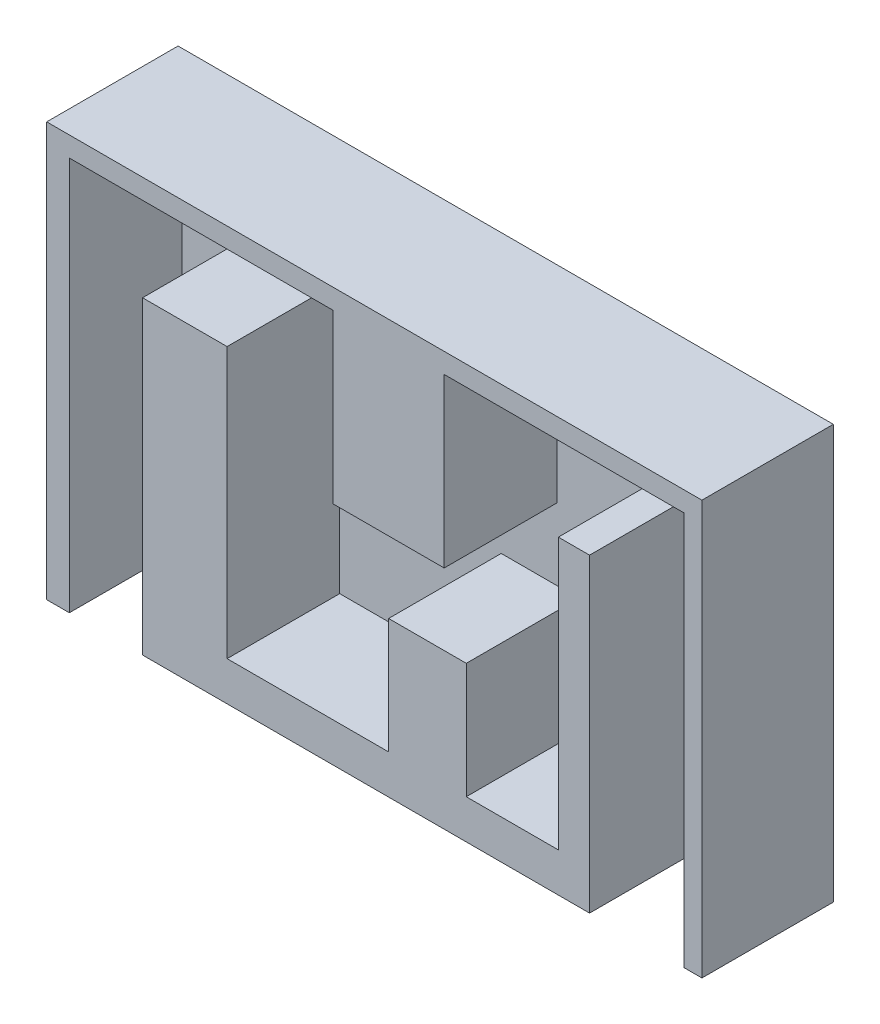
from build123d import *

# Parameters (mm, degrees)
SKETCH1_W           = 17456.171444087
SKETCH1_H           = 11024.95038574
BOSS_EXTRUDE1_DEPTH = 500
BOSS_EXTRUDE2_DEPTH = 3000


with BuildPart() as part:
    # Sketch1 → Boss-Extrude1 (new body)
    with BuildSketch(Plane.XY):
        with Locations((675.548430499, -513.416807179)):
            Rectangle(SKETCH1_W, SKETCH1_H)
    extrude(amount=BOSS_EXTRUDE1_DEPTH)

    # Sketch2 → Boss-Extrude2 (add)
    with BuildSketch(Plane.XY.offset(500)):
        Polygon((-8052.537291545, -6025.892000049), (-7448.807383296, -6025.892000049), (-7448.807383296, 4466.462823429), (-423.437109904, 4466.462823429), (-423.437109904, 0), (2536.686791274, 0), (2536.686791274, 4466.462823429), (8924.388706678, 4466.462823429), (8924.388706678, -6025.892000049), (9403.634152542, -6025.892000049), (9403.634152542, 4466.462823429), (9403.634152542, 4999.058385691), (-7448.807383296, 4999.058385691), (-8052.537291545, 4999.058385691), align=None)
        Polygon((3125.306231796, -4983.032925661), (5578.019741258, -4983.032925661), (5578.019741258, 2233.231411715), (6409.754725538, 2233.231411715), (6409.754725538, -4983.032925661), (6409.754725538, -6025.892000049), (-3246.47736203, -6025.892000049), (-5498.847673456, -6025.892000049), (-5498.847673456, 2217.430041705), (-3246.47736203, 2217.430041705), (-3246.47736203, -4983.032925661), (1056.624840685, -4983.032925661), (1056.624840685, -1904.230979172), (3125.306231796, -1904.230979172), align=None)
    extrude(amount=BOSS_EXTRUDE2_DEPTH)


solid = part.part
